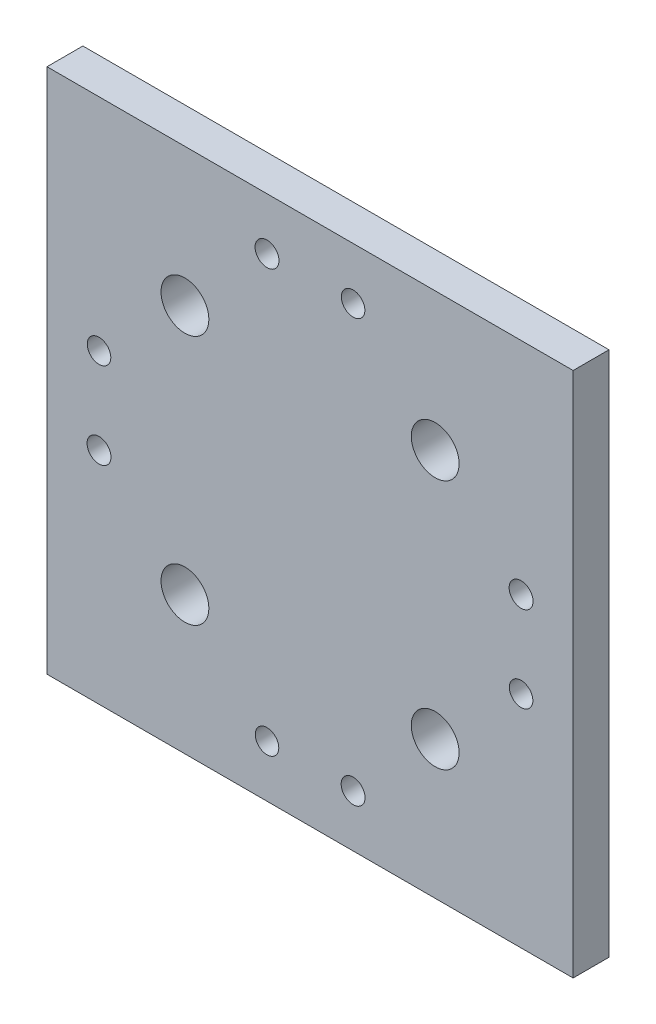
from build123d import *

# Parameters (mm, degrees)
SKETCH1_W                  = 139.7
SKETCH1_H                  = 139.7
EXTRUDE1_DEPTH             = 9.525
F_1_2_0_5_DIAMETER_HOLE1_D = 12.7
CIRPATTERN1_COUNT          = 4


with BuildPart() as part:
    # Sketch1 → Extrude1 (new body)
    with BuildSketch(Plane.XY):
        Rectangle(SKETCH1_W, SKETCH1_H)
    extrude(amount=EXTRUDE1_DEPTH)

    # 1_2 _0.5_ Diameter Hole1 (through all)
    with Locations(Plane(origin=(-33.226947648, 33.226947648, 9.525), x_dir=(1, 0, 0), z_dir=(0, 0, 1))):
        with Locations((0, 0)):
            f_1_2_0_5_diameter_hole1 = Hole(F_1_2_0_5_DIAMETER_HOLE1_D / 2)

    # Sketch4 → D _0.246_ Diameter Hole1 (revolve, cut)
    with BuildSketch(Plane(origin=(-56.0324, 11.43, 9.525), x_dir=(0, -1, 0), z_dir=(1, 0, 0))):
        Polygon((0, 0), (0, 35.659208746), (3.1242, 33.782), (3.1242, 0), align=None)
    d_0_246_diameter_hole1 = revolve(axis=Axis((-56.0324, 11.43, 15.875), (0, 0, -1)), mode=Mode.SUBTRACT)

    # Sketch5 → 1_4 _0.25_ Diameter Hole1 (revolve, cut)
    with BuildSketch(Plane(origin=(-56.0324, -11.43, 9.525), x_dir=(0, -1, 0), z_dir=(1, 0, 0))):
        Polygon((0, 0), (0, 35.689732465), (3.175, 33.782), (3.175, 0), align=None)
    f_1_4_0_25_diameter_hole1 = revolve(axis=Axis((-56.0324, -11.43, 15.875), (0, 0, -1)), mode=Mode.SUBTRACT)

    # CirPattern1: 1_2 _0.5_ Diameter Hole1, D _0.246_ Diameter Hole1, 1_4 _0.25_ Diameter Hole1 ×4 about axis
    cirpattern1_axis = Axis((0, 0, -0.9525), (0, 0, 1))
    add([f_1_2_0_5_diameter_hole1.rotate(cirpattern1_axis, i * 360 / CIRPATTERN1_COUNT) for i in range(1, CIRPATTERN1_COUNT)], mode=Mode.SUBTRACT)
    add([d_0_246_diameter_hole1.rotate(cirpattern1_axis, i * 360 / CIRPATTERN1_COUNT) for i in range(1, CIRPATTERN1_COUNT)], mode=Mode.SUBTRACT)
    add([f_1_4_0_25_diameter_hole1.rotate(cirpattern1_axis, i * 360 / CIRPATTERN1_COUNT) for i in range(1, CIRPATTERN1_COUNT)], mode=Mode.SUBTRACT)


solid = part.part
